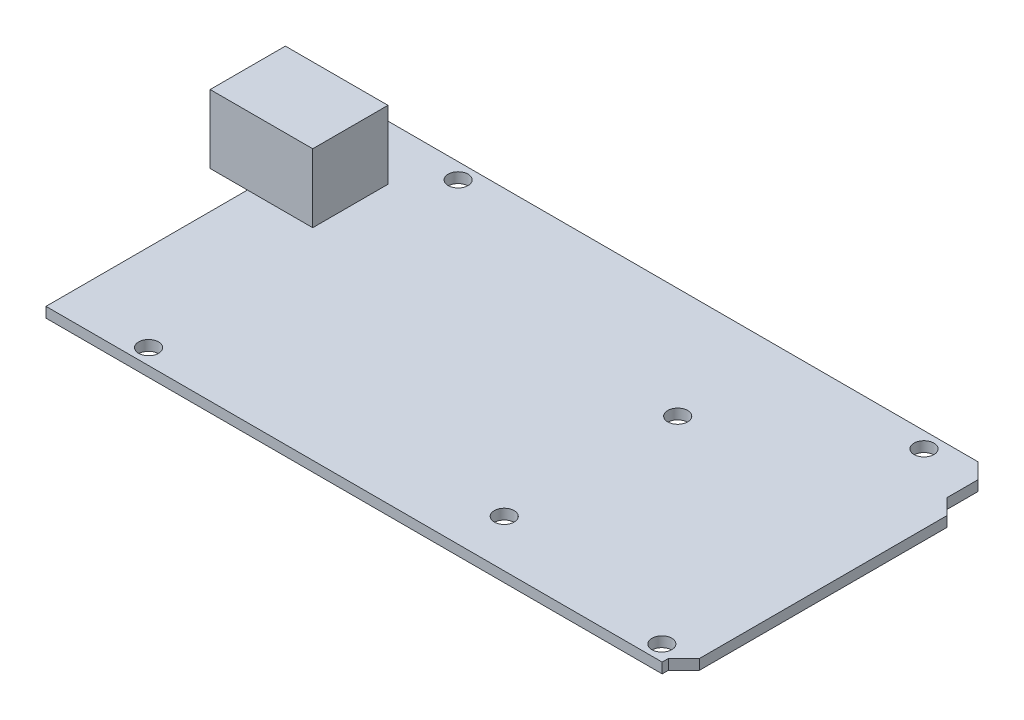
from build123d import *

# Parameters (mm, degrees)
SKETCH1_R           = 1.6
BOSS_EXTRUDE1_DEPTH = 1.65
SKETCH2_W           = 16.5
SKETCH2_H           = 12.1
BOSS_EXTRUDE2_DEPTH = 11


with BuildPart() as part:
    # Sketch1 → Boss-Extrude1 (new body)
    with BuildSketch(Plane(origin=(0, 0, 0), x_dir=(1, 0, 0), z_dir=(0, 1, 0))):
        Polygon((99.1, 0), (99.1, 1), (101.6, 3.5), (101.6, 43.3), (99.1, 45.8), (99.1, 50.8), (96.6, 53.3), (0, 53.3), (0, 0), align=None)
        with Locations((15.524, 50.76)):
            Circle(SKETCH1_R, mode=Mode.SUBTRACT)
        with Locations((14, 2.5)):
            Circle(SKETCH1_R, mode=Mode.SUBTRACT)
        with Locations((96.55, 2.5)):
            Circle(SKETCH1_R, mode=Mode.SUBTRACT)
        with Locations((90.454, 50.76)):
            Circle(SKETCH1_R, mode=Mode.SUBTRACT)
        with Locations((66.1, 35.5)):
            Circle(SKETCH1_R, mode=Mode.SUBTRACT)
        with Locations((66.1, 7.6)):
            Circle(SKETCH1_R, mode=Mode.SUBTRACT)
    extrude(amount=BOSS_EXTRUDE1_DEPTH)

    # Sketch2 → Boss-Extrude2 (add)
    with BuildSketch(Plane(origin=(0, 1.65, 0), x_dir=(1, 0, 0), z_dir=(0, 1, 0))):
        with Locations((2.25, 38.45)):
            Rectangle(SKETCH2_W, SKETCH2_H)
    extrude(amount=BOSS_EXTRUDE2_DEPTH)


solid = part.part
